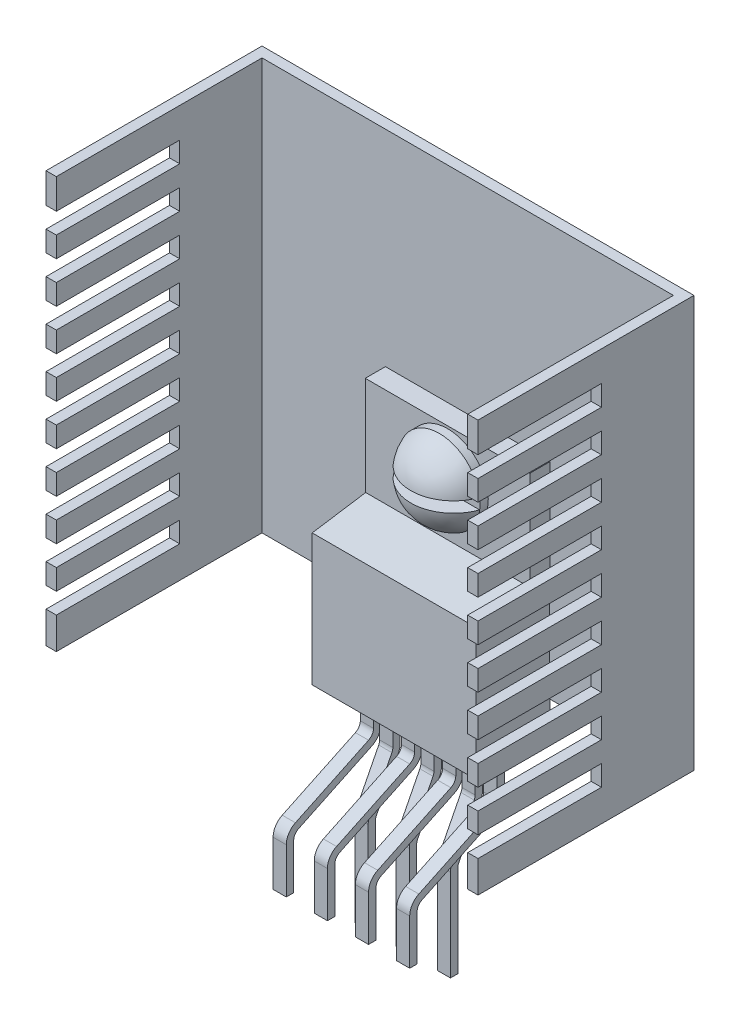
from build123d import *

# Parameters (mm, degrees)
SKETCH2_W                     = 10.16
SKETCH2_H                     = 4.572
BASE_EXTRUDE_DEPTH            = 14.732
CUT_EXTRUDE1_DEPTH            = 1
CUT_EXTRUDE1_DEPTH_BACK       = 11.16
CUT_EXTRUDE4_DEPTH            = 0.0254
CUT_EXTRUDE5_DEPTH            = 0.0254
CUT_EXTRUDE6_DEPTH            = 0.0254
BOSS_EXTRUDE_THIN1_DEPTH      = 0.4064
LPATTERN2_COUNT               = 4
LPATTERN2_PITCH               = 2.54
BOSS_EXTRUDE_THIN2_DEPTH      = 0.4064
LPATTERN3_COUNT               = 3
LPATTERN3_PITCH               = 2.54
BOSS_EXTRUDE_THIN3_DEPTH      = 12.7
BOSS_EXTRUDE_THIN3_DEPTH_BACK = 12.7
SKETCH4_R                     = 1.905
CUT_EXTRUDE2_DEPTH            = 14.732
SKETCH12_W                    = 7.62
SKETCH12_H                    = 1.27
CUT_EXTRUDE7_DEPTH            = 27.67
SKETCH13_R                    = 2.5146
BOSS_EXTRUDE1_DEPTH           = 0.508
DOME1_FACE_RADIUS             = 2.5146
DOME1_HEIGHT                  = 1.778
SKETCH14_W                    = 5.92296417
SKETCH14_H                    = 0.6604
CUT_EXTRUDE8_DEPTH            = 3.556
CUT_EXTRUDE8_DEPTH_BACK       = 0.508
BOSS_EXTRUDE2_DEPTH           = 1.27
SKETCH16_R                    = 1.5875
BOSS_EXTRUDE3_DEPTH           = 0.508


with BuildPart() as part:
    # Sketch2 → Base-Extrude (new body)
    with BuildSketch(Plane(origin=(0, 6.35, 0), x_dir=(-1, 0, 0), z_dir=(0, 1, 0))):
        with Locations((-3.81, -5.3086)):
            Rectangle(SKETCH2_W, SKETCH2_H)
    extrude(amount=BASE_EXTRUDE_DEPTH)

    # Sketch3 → Cut-Extrude1 (cut, two sides)
    with BuildSketch(Plane.ZY.offset(1.27)) as cut_extrude1_sk:
        Polygon((-6.3246, 21.082), (-6.3246, 14.986), (-3.0226, 14.478), (-3.0226, 21.082), align=None)
    extrude(amount=CUT_EXTRUDE1_DEPTH, mode=Mode.SUBTRACT)
    extrude(cut_extrude1_sk.sketch, amount=-CUT_EXTRUDE1_DEPTH_BACK, mode=Mode.SUBTRACT)

    # Sketch5 → Cut-Extrude4 (cut)
    with BuildSketch(Plane.ZY.offset(1.27)):
        Polygon((-7.5946, 15.181384615), (-3.0226, 14.478), (-3.0226, 6.35), (-7.5946, 6.35), align=None)
    extrude(amount=-CUT_EXTRUDE4_DEPTH, mode=Mode.SUBTRACT)

    # Sketch6 → Cut-Extrude5 (cut)
    with BuildSketch(Plane(origin=(8.89, 0, 0), x_dir=(0, 0, -1), z_dir=(1, 0, 0))):
        Polygon((3.0226, 14.478), (7.5946, 15.181384615), (7.5946, 6.35), (3.0226, 6.35), align=None)
    extrude(amount=-CUT_EXTRUDE5_DEPTH, mode=Mode.SUBTRACT)

    # Sketch7 → Cut-Extrude6 (cut)
    with BuildSketch(Plane(origin=(0, 0, -7.5946), x_dir=(-1, 0, 0), z_dir=(0, 0, -1))):
        Polygon((-8.89, 21.082), (-8.89, 15.181384615), (-7.62, 15.181384615), (-7.62, 9.652), (0, 9.652), (0, 15.181384615), (1.27, 15.181384615), (1.27, 21.082), align=None)
    extrude(amount=-CUT_EXTRUDE6_DEPTH, mode=Mode.SUBTRACT)

    # Sketch9 → Boss-Extrude-Thin1 (add, symmetric)
    with BuildSketch(Plane(origin=(0, 0, 0), x_dir=(0, 0, -1), z_dir=(1, 0, 0))):
        with BuildLine():
            Line((5.1562, 6.35), (5.1562, 3.7846))
            ThreePointArc((5.1562, 3.7846), (5.07392687, 3.499994822), (4.852487561, 3.303186265))
            Line((4.852487561, 3.303186265), (0.335437388, 1.14805408))
            ThreePointArc((0.335437388, 1.14805408), (-0.075807043, 0.782552474), (-0.2286, 0.254))
            Line((-0.2286, 0.254), (-0.2286, -2.54))
            Line((-0.2286, -2.54), (0.2286, -2.54))
            Line((0.2286, -2.54), (0.2286, 0.254))
            ThreePointArc((0.2286, 0.254), (0.31087313, 0.538605178), (0.532312439, 0.735413735))
            Line((0.532312439, 0.735413735), (5.049362612, 2.89054592))
            ThreePointArc((5.049362612, 2.89054592), (5.460607043, 3.256047526), (5.6134, 3.7846))
            Line((5.6134, 3.7846), (5.6134, 6.35))
            Line((5.6134, 6.35), (5.1562, 6.35))
        make_face()
    boss_extrude_thin1 = extrude(amount=BOSS_EXTRUDE_THIN1_DEPTH, both=True)

    # LPattern2: Boss-Extrude-Thin1 ×4
    with Locations(*[(i * LPATTERN2_PITCH, 0, 0) for i in range(1, LPATTERN2_COUNT)]):
        add(boss_extrude_thin1)

    # Sketch10 → Boss-Extrude-Thin2 (add, symmetric)
    with BuildSketch(Plane(origin=(1.27, 0, 0), x_dir=(0, 0, -1), z_dir=(1, 0, 0))):
        with BuildLine():
            Line((5.08, 6.35), (5.08, 3.433803724))
            ThreePointArc((5.08, 3.433803724), (5.065314035, 3.309500424), (5.022064828, 3.192041946))
            Line((5.022064828, 3.192041946), (3.66359389, 0.520382434))
            ThreePointArc((3.66359389, 0.520382434), (3.583273936, 0.302245261), (3.556, 0.071396276))
            Line((3.556, 0.071396276), (3.556, -5.588))
            Line((3.556, -5.588), (4.0132, -5.588))
            Line((4.0132, -5.588), (4.0132, 0.071396276))
            ThreePointArc((4.0132, 0.071396276), (4.027885965, 0.195699576), (4.071135172, 0.313158054))
            Line((4.071135172, 0.313158054), (5.42960611, 2.984817566))
            ThreePointArc((5.42960611, 2.984817566), (5.509926064, 3.202954739), (5.5372, 3.433803724))
            Line((5.5372, 3.433803724), (5.5372, 6.35))
            Line((5.5372, 6.35), (5.08, 6.35))
        make_face()
    boss_extrude_thin2 = extrude(amount=BOSS_EXTRUDE_THIN2_DEPTH, both=True)

    # LPattern3: Boss-Extrude-Thin2 ×3
    with Locations(*[(i * LPATTERN3_PITCH, 0, 0) for i in range(1, LPATTERN3_COUNT)]):
        add(boss_extrude_thin2)

    # Sketch11 → Boss-Extrude-Thin3 (add, two sides)
    with BuildSketch(Plane(origin=(0, 21.082, 0), x_dir=(-1, 0, 0), z_dir=(0, 1, 0))) as boss_extrude_thin3_sk:
        Polygon((-16.51, 5.1308), (-16.51, -7.5692), (8.89, -7.5692), (8.89, 5.1308), (9.525, 5.1308), (9.525, -8.2042), (-17.145, -8.2042), (-17.145, 5.1308), align=None)
    extrude(amount=BOSS_EXTRUDE_THIN3_DEPTH)
    extrude(boss_extrude_thin3_sk.sketch, amount=-BOSS_EXTRUDE_THIN3_DEPTH_BACK)

    # Sketch4 → Cut-Extrude2 (cut)
    with BuildSketch(Plane.XY.offset(-6.3246)):
        with Locations((3.81, 18.415)):
            Circle(SKETCH4_R)
    extrude(amount=-CUT_EXTRUDE2_DEPTH, mode=Mode.SUBTRACT)

    # Sketch12 → Cut-Extrude7 (cut, through all)
    with BuildSketch(Plane(origin=(17.145, 0, 0), x_dir=(0, 0, -1), z_dir=(1, 0, 0))):
        with Locations((-1.3208, 31.2928)):
            Rectangle(SKETCH12_W, SKETCH12_H)
        with Locations((-1.3208, 28.7528)):
            Rectangle(SKETCH12_W, SKETCH12_H)
        with Locations((-1.3208, 26.2128)):
            Rectangle(SKETCH12_W, SKETCH12_H)
        with Locations((-1.3208, 23.6728)):
            Rectangle(SKETCH12_W, SKETCH12_H)
        with Locations((-1.3208, 21.1328)):
            Rectangle(SKETCH12_W, SKETCH12_H)
        with Locations((-1.3208, 18.5928)):
            Rectangle(SKETCH12_W, SKETCH12_H)
        with Locations((-1.3208, 16.0528)):
            Rectangle(SKETCH12_W, SKETCH12_H)
        with Locations((-1.3208, 13.5128)):
            Rectangle(SKETCH12_W, SKETCH12_H)
        with Locations((-1.3208, 10.9728)):
            Rectangle(SKETCH12_W, SKETCH12_H)
    extrude(amount=-CUT_EXTRUDE7_DEPTH, mode=Mode.SUBTRACT)

    # Sketch13 → Boss-Extrude1 (add)
    with BuildSketch(Plane.XY.offset(-6.3246)):
        with Locations((3.81, 18.415)):
            Circle(SKETCH13_R)
    extrude(amount=BOSS_EXTRUDE1_DEPTH)

    # Dome1: a dome of height H over a round flat face of radius A is a cap of a sphere of radius (A * A + H * H) / (2 * H)
    dome1_r = (DOME1_FACE_RADIUS * DOME1_FACE_RADIUS + DOME1_HEIGHT * DOME1_HEIGHT) / (2 * DOME1_HEIGHT)
    dome1_base = Plane((3.81, 18.415, -5.8166), z_dir=(0, 0, 1))
    with Locations(dome1_base.offset(DOME1_HEIGHT - dome1_r)):
        dome1_ball = Sphere(dome1_r, mode=Mode.PRIVATE)
    add(split(dome1_ball, bisect_by=dome1_base, keep=Keep.TOP, mode=Mode.PRIVATE))

    # Sketch14 → Cut-Extrude8 (cut, two sides)
    with BuildSketch(Plane.XY.offset(-5.3086)) as cut_extrude8_sk:
        with Locations((3.544332758, 18.415)):
            Rectangle(SKETCH14_W, SKETCH14_H)
    extrude(amount=CUT_EXTRUDE8_DEPTH, mode=Mode.SUBTRACT)
    extrude(cut_extrude8_sk.sketch, amount=-CUT_EXTRUDE8_DEPTH_BACK, mode=Mode.SUBTRACT)

    # Sketch15 → Boss-Extrude2 (add)
    with BuildSketch(Plane(origin=(0, 0, -8.2042), x_dir=(-1, 0, 0), z_dir=(0, 0, -1))):
        Polygon((-6.950885521, 17.903644391), (-4.937595813, 15.439235544), (-1.796710292, 15.950591153), (-0.669114479, 18.926355609), (-2.682404187, 21.390764456), (-5.823289708, 20.879408847), align=None)
    extrude(amount=BOSS_EXTRUDE2_DEPTH)

    # Sketch16 → Boss-Extrude3 (add)
    with BuildSketch(Plane(origin=(0, 0, -9.4742), x_dir=(-1, 0, 0), z_dir=(0, 0, -1))):
        with Locations((-3.81, 18.415)):
            Circle(SKETCH16_R)
    extrude(amount=BOSS_EXTRUDE3_DEPTH)

    # Sketch18 → Cut-Revolve1 (revolve, cut)
    with BuildSketch(Plane(origin=(3.81, 0, 0), x_dir=(0, 0, -1), z_dir=(1, 0, 0))):
        Polygon((8.868218503, 22.080720867), (10.118389959, 19.04115565), (11.181263168, 19.478314801), (9.931091711, 22.517880017), align=None)
    revolve(axis=Axis((3.81, 18.415, -6.938037772), (0, 0, -1)), mode=Mode.SUBTRACT)


solid = part.part
